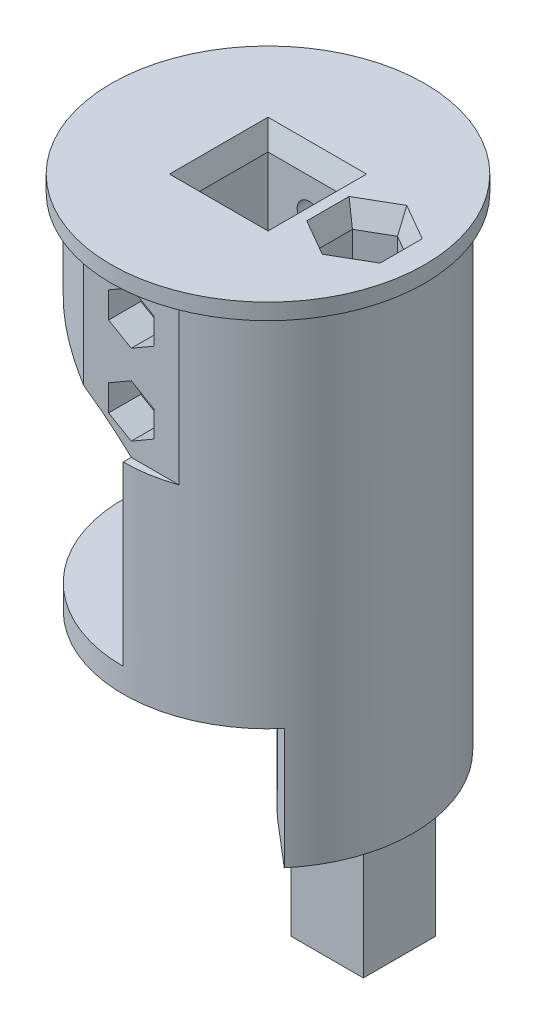
from build123d import *
from build123d.topology import SkipClean

# Parameters (mm, degrees)
SKETCH_1_R          = 18
EXTRUDE_1_DEPTH     = 45
SKETCH_2_R          = 19.5
EXTRUDE_2_DEPTH     = 2
SKETCH_3_W          = 10.25
SKETCH_3_H          = 10.25
CUT_EXTRUDE_1_DEPTH = 40
EXTRUDE_3_DEPTH     = 15
SKETCH1_R           = 18
BOSS_EXTRUDE1_DEPTH = 20
SKETCH3_R           = 18
BOSS_EXTRUDE2_DEPTH = 7
SKETCH4_W           = 10.2
SKETCH4_H           = 10.2
CUT_EXTRUDE2_DEPTH  = 27
CUT_EXTRUDE4_DEPTH  = 25
BOSS_EXTRUDE3_DEPTH = 3
SKETCH9_W           = 36
SKETCH9_H           = 22
CUT_EXTRUDE5_DEPTH  = 8
SKETCH10_R          = 3.7
SKETCH10_W          = 3
SKETCH10_H          = 2
CUT_EXTRUDE6_DEPTH  = 10
SKETCH11_R          = 2
CUT_EXTRUDE7_DEPTH  = 102
SKETCH15_R          = 18
CUT_EXTRUDE9_DEPTH  = 27
CUT_EXTRUDE11_DEPTH = 20
SKETCH18_R          = 1.5
CUT_EXTRUDE12_DEPTH = 63.62188116
SKETCH19_R          = 3
CUT_EXTRUDE13_DEPTH = 3
BOSS_EXTRUDE5_DEPTH = 22
CUT_EXTRUDE16_DEPTH = 4
CUT_EXTRUDE17_DEPTH = 6
CUT_EXTRUDE18_DEPTH = 63.62188116
FILLET2_R           = 5
SKETCH30_W          = 18.8
SKETCH30_H          = 10
CUT_EXTRUDE20_DEPTH = 3
CHAMFER1_SIZE       = 1
CHAMFER1_SIZE2      = 2.747477419
CHAMFER2_SIZE       = 1
CHAMFER2_SIZE2      = 2.747477419
SKETCH37_W          = 9
SKETCH37_H          = 9
SKETCH37_R          = 2
BOSS_EXTRUDE7_DEPTH = 15
CUT_EXTRUDE22_DEPTH = 15
CUT_EXTRUDE23_REACH = 69.856
SKETCH40_W          = 4.363156696
SKETCH40_H          = 4.363156696
CUT_EXTRUDE24_DEPTH = 10
FILLET7_R           = 6


with BuildPart() as part:
    # Эскиз1 → Бобышка-Вытянуть1 (new body)
    with BuildSketch(Plane(origin=(0, 0, 0), x_dir=(1, 0, 0), z_dir=(0, 1, 0))):
        with Locations(Location((0, 0, 0), (0, 0, 90))):
            Circle(SKETCH_1_R)
    extrude(amount=EXTRUDE_1_DEPTH)

    # Эскиз2 → Бобышка-Вытянуть2 (add)
    with BuildSketch(Plane(origin=(0, 45, 0), x_dir=(1, 0, 0), z_dir=(0, 1, 0))):
        with Locations(Location((0, 0, 0), (0, 0, 270))):
            Circle(SKETCH_2_R)
    extrude(amount=EXTRUDE_2_DEPTH)

    # Эскиз3 → Вырез-Вытянуть1 (cut)
    with BuildSketch(Plane(origin=(0, 47, 0), x_dir=(1, 0, 0), z_dir=(0, 1, 0))):
        Rectangle(SKETCH_3_W, SKETCH_3_H)
    extrude(amount=-CUT_EXTRUDE_1_DEPTH, mode=Mode.SUBTRACT)

    # Эскиз4 → Бобышка-Вытянуть3 (add)
    with BuildSketch(Plane.XZ):
        with BuildLine():
            Line((5.142300877, -6.128355545), (11.570176974, -13.788799976))
            ThreePointArc((11.570176974, -13.788799976), (17.937391115, -1.5), (13.69961987, 11.675633406))
            Line((13.69961987, 11.675633406), (5.142300877, 4.38257561))
            Line((5.142300877, 4.38257561), (5.142300877, -6.128355545))
        make_face()
    extrude(amount=EXTRUDE_3_DEPTH)

    # Sketch1 → Boss-Extrude1 (add)
    with BuildSketch(Plane.XZ.offset(15)):
        with Locations(Location((0, 0, 0), (0, 0, 270))):
            Circle(SKETCH1_R)
    extrude(amount=BOSS_EXTRUDE1_DEPTH)

    # Sketch3 → Boss-Extrude2 (add)
    with BuildSketch(Plane.XZ.offset(35)):
        with Locations(Location((0, 0, 0), (0, 0, 270))):
            Circle(SKETCH3_R)
    extrude(amount=BOSS_EXTRUDE2_DEPTH)

    # Sketch4 → Cut-Extrude2 (cut)
    with BuildSketch(Plane.XZ.offset(42)):
        Rectangle(SKETCH4_W, SKETCH4_H)
    extrude(amount=-CUT_EXTRUDE2_DEPTH, mode=Mode.SUBTRACT)

    # Sketch6 → Cut-Extrude4 (cut)
    with BuildSketch(Plane.XZ):
        with BuildLine():
            Line((0, 18), (0, -18))
            ThreePointArc((0, -18), (-18, 0), (0, 18))
        make_face()
    extrude(amount=-CUT_EXTRUDE4_DEPTH, mode=Mode.SUBTRACT)

    # Sketch8 → Boss-Extrude3 (add)
    with BuildSketch(Plane.XZ):
        with BuildLine():
            Line((0, -18), (0, 18))
            ThreePointArc((0, 18), (-18, 0), (0, -18))
        make_face()
    extrude(amount=-BOSS_EXTRUDE3_DEPTH)

    # Sketch9 → Cut-Extrude5 (cut)
    with BuildSketch(Plane.ZY):
        with Locations((0, 14)):
            Rectangle(SKETCH9_W, SKETCH9_H)
    extrude(amount=-CUT_EXTRUDE5_DEPTH, mode=Mode.SUBTRACT)

    # Sketch10 → Cut-Extrude6 (cut)
    with BuildSketch(Plane.XZ):
        with Locations(Location((0, 0, 0), (0, 0, 270))):
            Circle(SKETCH10_R)
        with Locations((0, 7.7)):
            Rectangle(SKETCH10_W, SKETCH10_H)
    extrude(amount=-CUT_EXTRUDE6_DEPTH, mode=Mode.SUBTRACT)

    # Sketch11 → Cut-Extrude7 (cut)
    with BuildSketch(Plane.XZ.offset(42)):
        with Locations(Location((12, 0, 0), (0, 0, 270))):
            Circle(SKETCH11_R)
    extrude(amount=-CUT_EXTRUDE7_DEPTH, mode=Mode.SUBTRACT)

    # Sketch15 → Cut-Extrude9 (cut)
    with BuildSketch(Plane.XZ.offset(42)):
        with Locations(Location((0, 0, 0), (0, 0, 310))):
            Circle(SKETCH15_R)
    extrude(amount=-CUT_EXTRUDE9_DEPTH, mode=Mode.SUBTRACT)

    # Sketch17 → Cut-Extrude11 (cut)
    with BuildSketch(Plane.XZ.offset(-25)):
        with BuildLine():
            Line((5.916079783, -17), (-5.916079783, -17))
            ThreePointArc((-5.916079783, -17), (0, -18), (5.916079783, -17))
        make_face()
        with BuildLine():
            Line((5.916079783, 17), (-5.916079783, 17))
            ThreePointArc((-5.916079783, 17), (0, 18), (5.916079783, 17))
        make_face()
    extrude(amount=-CUT_EXTRUDE11_DEPTH, mode=Mode.SUBTRACT)

    # Sketch18 → Cut-Extrude12 (cut, through all)
    with BuildSketch(Plane.XY.offset(-17)):
        with Locations(Location((0, 30, 0), (0, 0, 180))):
            Circle(SKETCH18_R)
        with Locations(Location((0, 40, 0), (0, 0, 180))):
            Circle(SKETCH18_R)
    extrude(amount=CUT_EXTRUDE12_DEPTH, mode=Mode.SUBTRACT)

    # Sketch19 → Cut-Extrude13 (cut)
    with BuildSketch(Plane.XY.offset(-17)):
        with Locations((0, 30)):
            Circle(SKETCH19_R)
        with Locations((0, 40)):
            Circle(SKETCH19_R)
    extrude(amount=CUT_EXTRUDE13_DEPTH, mode=Mode.SUBTRACT)

    # Sketch23 → Boss-Extrude5 (add)
    with SkipClean():  # the faces are left unmerged after this step: merging them gives an invalid solid
        with BuildSketch(Plane(origin=(0, 3, 0), x_dir=(1, 0, 0), z_dir=(0, 1, 0))):
            with BuildLine():
                Line((0, -14.4), (8, -14.4))
                Line((8, -14.4), (8, -16.124515497))
                ThreePointArc((8, -16.124515497), (4.108449894, -17.524857759), (0, -18))
                Line((0, -18), (0, -14.4))
            make_face()
            with BuildLine():
                Line((0, 14.4), (8, 14.4))
                Line((8, 14.4), (8, 16.124515497))
                ThreePointArc((8, 16.124515497), (4.108449894, 17.524857759), (0, 18))
                Line((0, 18), (0, 14.4))
            make_face()
        extrude(amount=BOSS_EXTRUDE5_DEPTH)

    # Sketch25 → Cut-Extrude16 (cut)
    with SkipClean():  # the faces are left unmerged after this step: merging them gives an invalid solid
        with BuildSketch(Plane.XY.offset(17)):
            Polygon((-2.814582562, 28.375), (0, 26.75), (2.814582562, 28.375), (2.814582562, 31.625), (0, 33.25), (-2.814582562, 31.625), align=None)
            Polygon((-2.814582562, 41.625), (-2.814582562, 38.375), (0, 36.75), (2.814582562, 38.375), (2.814582562, 41.625), (0, 43.25), align=None)
        extrude(amount=-CUT_EXTRUDE16_DEPTH, mode=Mode.SUBTRACT)

    # Sketch26 → Cut-Extrude17 (cut)
    with SkipClean():  # the faces are left unmerged after this step: merging them gives an invalid solid
        with BuildSketch(Plane(origin=(0, 47, 0), x_dir=(1, 0, 0), z_dir=(0, 1, 0))):
            Polygon((8.449295844, -2.05), (12, -4.1), (15.550704156, -2.05), (15.550704156, 2.05), (12, 4.1), (8.449295844, 2.05), align=None)
        extrude(amount=-CUT_EXTRUDE17_DEPTH, mode=Mode.SUBTRACT)

    # Sketch27 → Cut-Extrude18 (cut, through all)
    with SkipClean():  # the faces are left unmerged after this step: merging them gives an invalid solid
        with BuildSketch(Plane.XY.offset(17)):
            with BuildLine():
                Line((-20, 36.547005384), (-20, 25))
                Line((-20, 25), (0, 25))
                ThreePointArc((0, 25), (-9.324199199, 31.944024015), (-20, 36.547005384))
            make_face()
        extrude(amount=-CUT_EXTRUDE18_DEPTH, mode=Mode.SUBTRACT)

    # Fillet2
    fillet2_edges = [part.edges().sort_by_distance(p)[0] for p in [
        (8, 14, -14.4),
        (8, 14, 14.4),
    ]]
    fillet(fillet2_edges, radius=FILLET2_R)

    # Sketch30 → Cut-Extrude20 (cut)
    with SkipClean():  # the faces are left unmerged after this step: merging them gives an invalid solid
        with BuildSketch(Plane.ZY.offset(-8)):
            with Locations((0, 8)):
                Rectangle(SKETCH30_W, SKETCH30_H)
        extrude(amount=-CUT_EXTRUDE20_DEPTH, mode=Mode.SUBTRACT)

    # Chamfer1
    chamfer1_edges = [part.edges().sort_by_distance(p)[0] for p in [
        (5.125, 47, 0),
        (0, 47, -5.125),
        (-5.125, 47, 0),
        (0, 47, 5.125),
    ]]
    chamfer1_side = [part.faces().sort_by_distance(p)[0] for p in [
        (0, 47, -18.948456711),
    ]]
    chamfer(chamfer1_edges, length=CHAMFER1_SIZE, length2=CHAMFER1_SIZE2, reference=chamfer1_side[0])

    # Chamfer2
    chamfer2_edges = [part.edges().sort_by_distance(p)[0] for p in [
        (8.449295844, 47, 0),
        (10.224647922, 47, 3.075),
        (13.775352078, 47, 3.075),
        (15.550704156, 47, 0),
        (13.775352078, 47, -3.075),
        (10.224647922, 47, -3.075),
    ]]
    chamfer2_side = [part.faces().sort_by_distance(p)[0] for p in [
        (6.676543289, 47, 0),
    ]]
    chamfer(chamfer2_edges, length=CHAMFER2_SIZE, length2=CHAMFER2_SIZE2, reference=chamfer2_side[0])

    # Sketch37 → Boss-Extrude7 (add)
    with SkipClean():  # the faces are left unmerged after this step: merging them gives an invalid solid
        with BuildSketch(Plane.XZ.offset(15)):
            with Locations((10.978822628, -0.872889968)):
                Rectangle(SKETCH37_W, SKETCH37_H)
            with Locations(Location((12, 0, 0), (0, 0, 270))):
                Circle(SKETCH37_R, mode=Mode.SUBTRACT)
        extrude(amount=BOSS_EXTRUDE7_DEPTH)

    # Sketch38 → Cut-Extrude22 (cut)
    with SkipClean():  # the faces are left unmerged after this step: merging them gives an invalid solid
        with BuildSketch(Plane.XZ.offset(15)):
            with BuildLine():
                Line((5.142300877, -6.128355545), (5.142300877, 4.38257561))
                ThreePointArc((5.142300877, 4.38257561), (5.978822628, -0.872889968), (5.142300877, -6.128355545))
            make_face()
        extrude(amount=-CUT_EXTRUDE22_DEPTH, mode=Mode.SUBTRACT)

    # Cut-Extrude23: up to this face of the body (flat: up to its plane)
    cut_extrude23_end = Plane(part.part.faces().sort_by_distance((9.450359937, 13, 0))[0])
    # Sketch39 → Cut-Extrude23 (cut, up to the picked face)
    with BuildSketch(Plane.XZ.offset(15), mode=Mode.PRIVATE) as cut_extrude23_sk1:
        with BuildLine():
            Line((7.420733648, -7.372889968), (15.420733648, -7.372889968))
            ThreePointArc((15.420733648, -7.372889968), (13.728515389, -10.030415688), (11.598853111, -12.352178848))
            Line((11.598853111, -12.352178848), (7.420733648, -7.372889968))
        make_face()
    cut_extrude23_tool1 = split(extrude(cut_extrude23_sk1.sketch, amount=-CUT_EXTRUDE23_REACH, mode=Mode.PRIVATE), bisect_by=cut_extrude23_end, keep=Keep.BOTH, mode=Mode.PRIVATE)
    add(cut_extrude23_tool1.solids().sort_by(Axis((11.596211, -15, -9.081847), (0, 1, 0)))[0], mode=Mode.SUBTRACT)

    # Sketch40 → Cut-Extrude24 (cut)
    with SkipClean():  # the faces are left unmerged after this step: merging them gives an invalid solid
        with BuildSketch(Plane(origin=(0, 3, 0), x_dir=(1, 0, 0), z_dir=(0, 1, 0))):
            with Locations((9.602311996, 9.554468316)):
                Rectangle(SKETCH40_W, SKETCH40_H)
        extrude(amount=CUT_EXTRUDE24_DEPTH, mode=Mode.SUBTRACT)

    # Fillet7
    fillet7_edges = [part.edges().sort_by_distance(p)[0] for p in [
        (5.142300877, -7.5, 4.38257561),
        (5.142300877, -7.5, -6.128355545),
    ]]
    fillet(fillet7_edges, radius=FILLET7_R)


solid = part.part
